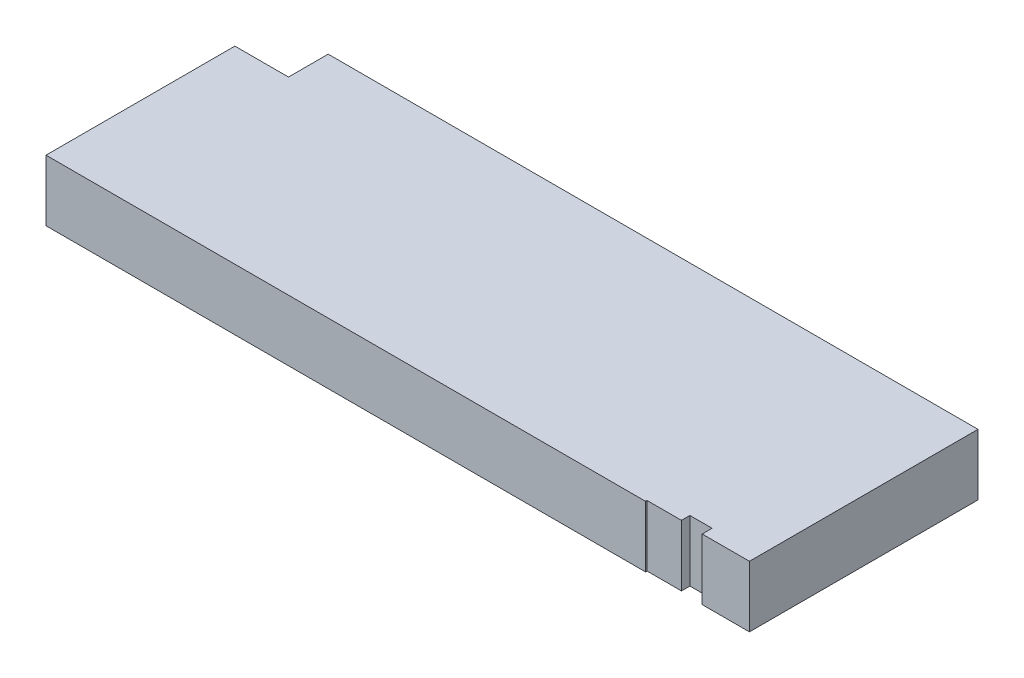
from build123d import *

# Parameters (mm, degrees)
BOSS_EXTRUDE1_DEPTH = 14.49


with BuildPart() as part:
    # Sketch1 → Boss-Extrude1 (new body)
    with BuildSketch(Plane(origin=(0, 0, 0), x_dir=(1, 0, 0), z_dir=(0, 1, 0))):
        Polygon((0, 0), (0, 44.75), (12.7, 44.75), (12.7, 54.15), (166.65, 54.15), (166.65, 0), (155.45, 0), (155.45, 2.35), (150.2, 2.35), (150.2, 0.35), (142.05, 0.35), (142.05, 0), align=None)
    extrude(amount=BOSS_EXTRUDE1_DEPTH)


solid = part.part
